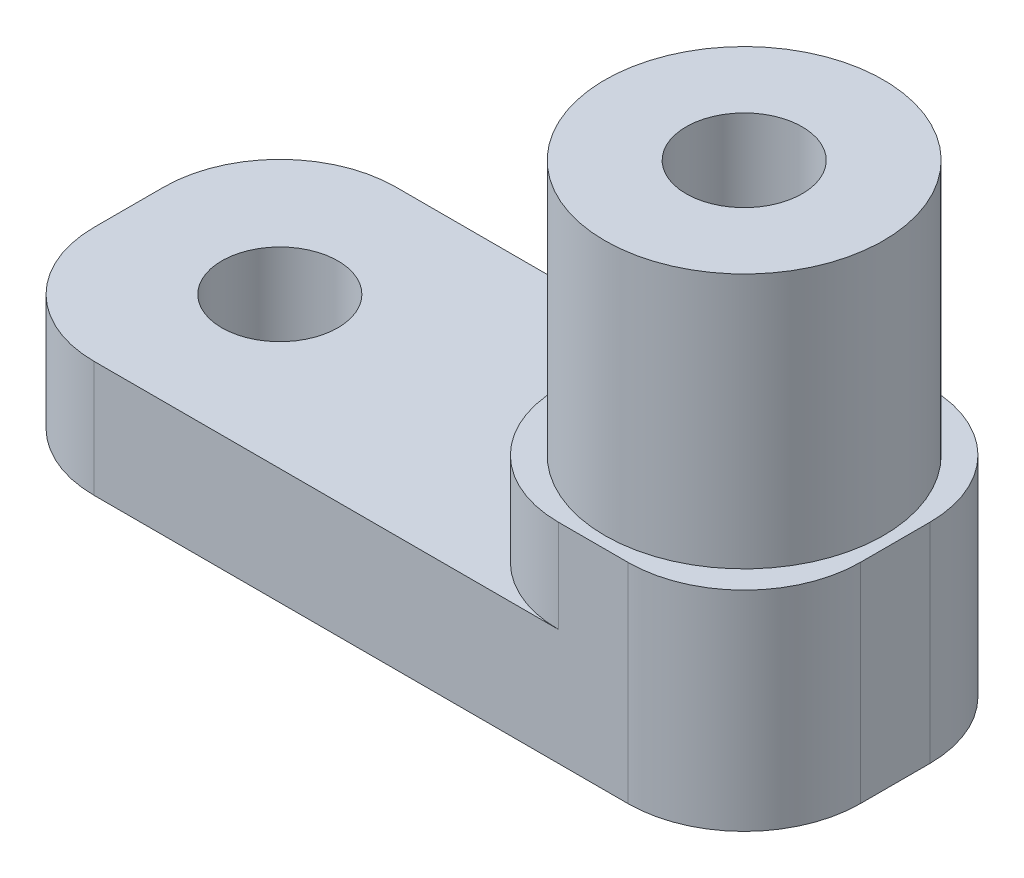
from build123d import *

# Parameters (mm, degrees)
SKETCH_1_W             = 33
SKETCH_1_H             = 13
SKETCH_1_R             = 2.23020675
EXTRUDE_1_DEPTH        = 5
SKETCH_1_5_R           = 6
EXTRUDE_2_DEPTH        = 20
HOLE_WIZARD_M6_1_D     = 5
HOLE_WIZARD_M6_2_D     = 5
SKETCH_10_W            = 13
SKETCH_10_H            = 13
SKETCH_10_R            = 6
EXTRUDE_3_DEPTH        = 4
HOLE_WIZARD_M4_1_D     = 3.3
HOLE_WIZARD_M4_1_DEPTH = 4
HOLE_WIZARD_M4_1_TIP   = 0.991420021
FILLET_1_R             = 5


with BuildPart() as part:
    # 草图1 → 凸台-拉伸1 (new body)
    with BuildSketch(Plane(origin=(0, 0, 0), x_dir=(1, 0, 0), z_dir=(0, 1, 0))):
        with Locations((-10, 0)):
            Rectangle(SKETCH_1_W, SKETCH_1_H)
        with Locations((-20, 0)):
            Circle(SKETCH_1_R, mode=Mode.SUBTRACT)
    extrude(amount=EXTRUDE_1_DEPTH)

    # 草图1<5> → 凸台-拉伸2 (add)
    with BuildSketch(Plane(origin=(0, 0, 0), x_dir=(1, 0, 0), z_dir=(0, 1, 0))):
        Circle(SKETCH_1_5_R)
    extrude(amount=EXTRUDE_2_DEPTH)

    # M6 螺纹孔1 (through all)
    with Locations(Plane(origin=(0, 20, 0), x_dir=(1, 0, 0), z_dir=(0, 1, 0))):
        with Locations((0, 0)):
            Hole(HOLE_WIZARD_M6_1_D / 2)

    # M6 螺纹孔2 (through all)
    with Locations(Plane(origin=(0, 5, 0), x_dir=(1, 0, 0), z_dir=(0, 1, 0))):
        with Locations((-20, 0)):
            Hole(HOLE_WIZARD_M6_2_D / 2)

    # 草图10 → 凸台-拉伸3 (add)
    with BuildSketch(Plane(origin=(0, 5, 0), x_dir=(1, 0, 0), z_dir=(0, 1, 0))):
        Rectangle(SKETCH_10_W, SKETCH_10_H)
        Circle(SKETCH_10_R, mode=Mode.SUBTRACT)
    extrude(amount=EXTRUDE_3_DEPTH)

    # M4 螺纹孔1
    with Locations(Plane(origin=(0, 0, 0), x_dir=(-1, 0, 0), z_dir=(0, -1, 0))):
        with Locations((7, 0)):
            Hole(HOLE_WIZARD_M4_1_D / 2, depth=HOLE_WIZARD_M4_1_DEPTH)
            with Locations((0, 0, -(HOLE_WIZARD_M4_1_DEPTH + HOLE_WIZARD_M4_1_TIP / 2))):  # 118° drill point
                Cone(0, HOLE_WIZARD_M4_1_D / 2, HOLE_WIZARD_M4_1_TIP, mode=Mode.SUBTRACT)

    # 圆角1
    fillet_1_edges = [part.edges().sort_by_distance(p)[0] for p in [
        (-6.5, 7, -6.5),
        (-6.5, 7, 6.5),
        (6.5, 4.5, 6.5),
        (6.5, 4.5, -6.5),
        (-26.5, 2.5, -6.5),
        (-26.5, 2.5, 6.5),
    ]]
    fillet(fillet_1_edges, radius=FILLET_1_R)


solid = part.part
